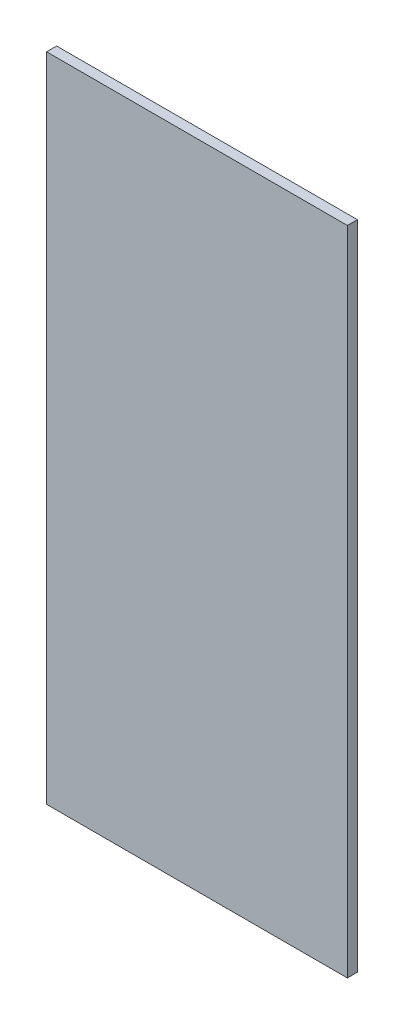
from build123d import *

# Parameters (mm, degrees)
SKETCH1_W           = 38.1
SKETCH1_H           = 82.55
BOSS_EXTRUDE1_DEPTH = 1.27


with BuildPart() as part:
    # Sketch1 → Boss-Extrude1 (new body)
    with BuildSketch(Plane.XY):
        with Locations((-19.05, 41.275)):
            Rectangle(SKETCH1_W, SKETCH1_H)
    extrude(amount=BOSS_EXTRUDE1_DEPTH)


solid = part.part
